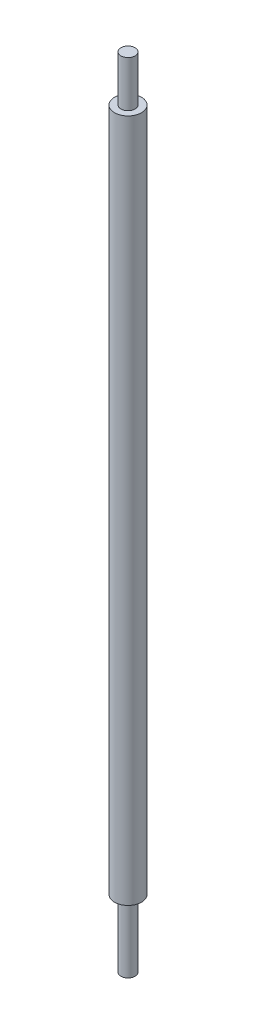
from build123d import *

# Parameters (mm, degrees)
SKETCH_1_R          = 7.6
EXTRUDE_1_DEPTH     = 450
SKETCH_2_R          = 7.6
SKETCH_2_R_2        = 4
CUT_EXTRUDE_1_DEPTH = 26
SKETCH_3_R          = 7.6
SKETCH_3_R_2        = 4
CUT_EXTRUDE_2_DEPTH = 38


with BuildPart() as part:
    # Эскиз1 → Бобышка-Вытянуть1 (new body)
    with BuildSketch(Plane(origin=(0, 0, 0), x_dir=(1, 0, 0), z_dir=(0, 1, 0))):
        Circle(SKETCH_1_R)
    extrude(amount=EXTRUDE_1_DEPTH)

    # Эскиз2 → Вырез-Вытянуть1 (cut)
    with BuildSketch(Plane(origin=(0, 450, 0), x_dir=(1, 0, 0), z_dir=(0, 1, 0))):
        Circle(SKETCH_2_R)
        Circle(SKETCH_2_R_2, mode=Mode.SUBTRACT)
    extrude(amount=-CUT_EXTRUDE_1_DEPTH, mode=Mode.SUBTRACT)

    # Эскиз3 → Вырез-Вытянуть2 (cut)
    with BuildSketch(Plane.XZ):
        Circle(SKETCH_3_R)
        Circle(SKETCH_3_R_2, mode=Mode.SUBTRACT)
    extrude(amount=-CUT_EXTRUDE_2_DEPTH, mode=Mode.SUBTRACT)


solid = part.part
